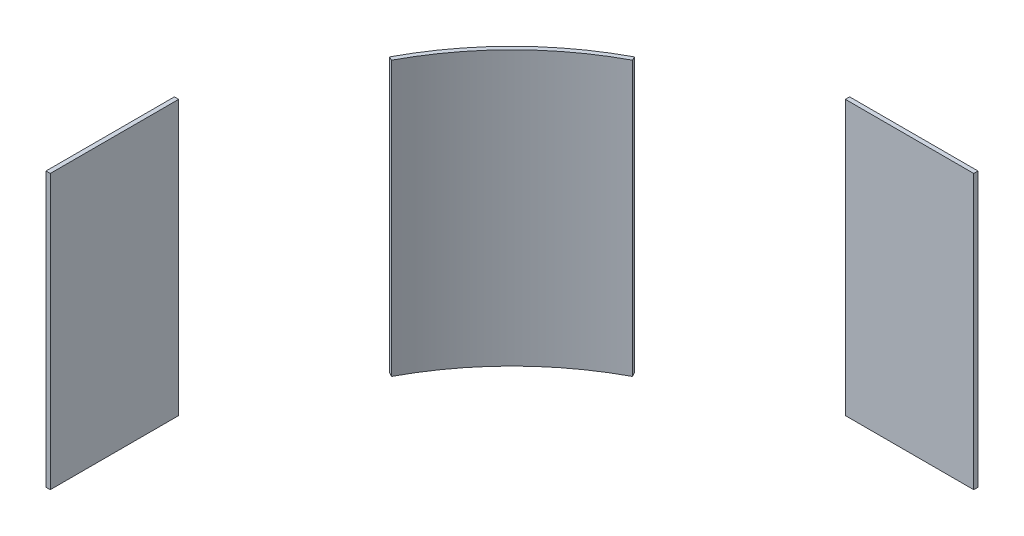
from build123d import *

# Parameters (mm, degrees)
SKETCH1_W        = 0.25
SKETCH1_H        = 7.5
EXTRUDE1_DEPTH   = 8
SKETCH1_W_2      = 7.5
SKETCH1_H_2      = 0.25
EXTRUDE1_2_DEPTH = 8
EXTRUDE1_3_DEPTH = 8


with BuildPart() as part:
    # Sketch1 → Extrude1 (new body, symmetric)
    with BuildSketch(Plane(origin=(0, 0, 0), x_dir=(1, 0, 0), z_dir=(0, 1, 0))):
        with Locations((-19.375, -3.97)):
            Rectangle(SKETCH1_W, SKETCH1_H)
    extrude(amount=EXTRUDE1_DEPTH, both=True)


with BuildPart() as body_2:
    # Sketch1 → Extrude1 2 (new body, symmetric)
    with BuildSketch(Plane(origin=(0, 0, 0), x_dir=(1, 0, 0), z_dir=(0, 1, 0))):
        with Locations((3.97, 19.375)):
            Rectangle(SKETCH1_W_2, SKETCH1_H_2)
    extrude(amount=EXTRUDE1_2_DEPTH, both=True)


with BuildPart() as body_3:
    # Sketch1 → Extrude1 3 (new body, symmetric)
    with BuildSketch(Plane(origin=(0, 0, 0), x_dir=(1, 0, 0), z_dir=(0, 1, 0))):
        with BuildLine():
            Line((-8.091263553, 15.234630094), (-7.973998864, 15.013838354))
            ThreePointArc((-7.973998864, 15.013838354), (-12.02081528, 12.02081528), (-15.013838354, 7.973998864))
            Line((-15.013838354, 7.973998864), (-15.234630094, 8.091263553))
            ThreePointArc((-15.234630094, 8.091263553), (-12.197591975, 12.197591975), (-8.091263553, 15.234630094))
        make_face()
    extrude(amount=EXTRUDE1_3_DEPTH, both=True)


solid = Compound([part.part, body_2.part, body_3.part])
